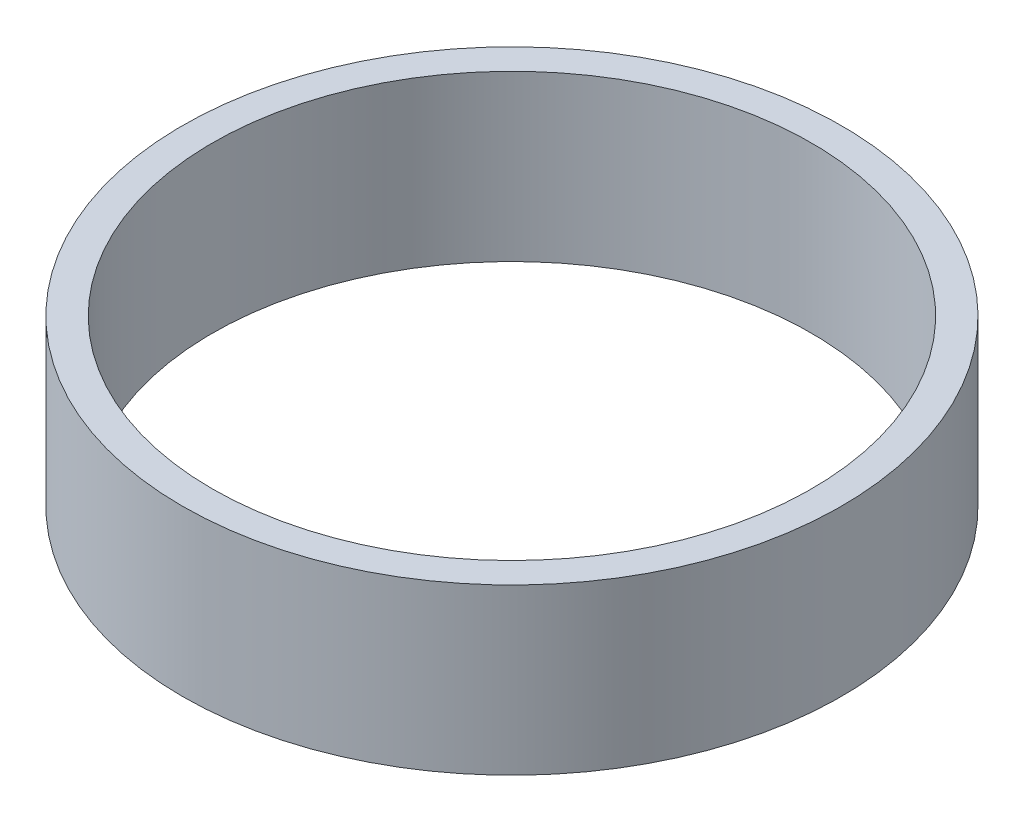
from build123d import *

# Parameters (mm, degrees)
SKETCH1_R           = 44
SKETCH1_R_2         = 40
BOSS_EXTRUDE1_DEPTH = 22


with BuildPart() as part:
    # Sketch1 → Boss-Extrude1 (new body)
    with BuildSketch(Plane(origin=(0, 0, 0), x_dir=(1, 0, 0), z_dir=(0, 1, 0))):
        Circle(SKETCH1_R)
        Circle(SKETCH1_R_2, mode=Mode.SUBTRACT)
    extrude(amount=BOSS_EXTRUDE1_DEPTH)


solid = part.part
